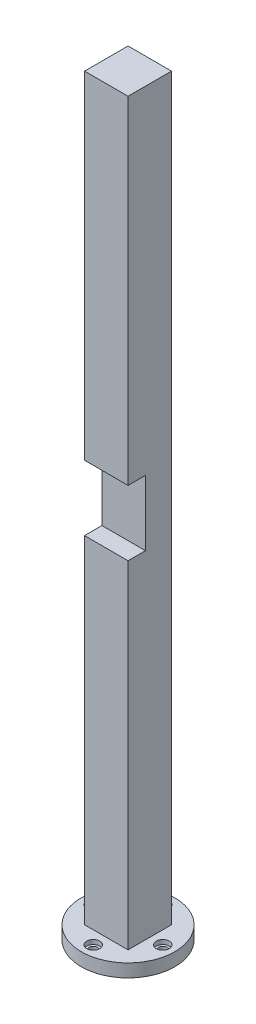
from build123d import *

# Parameters (mm, degrees)
SKETCH1_W           = 10
SKETCH1_H           = 10
BOSS_EXTRUDE1_DEPTH = 85
SKETCH2_W           = 10
SKETCH2_H           = 15
CUT_EXTRUDE1_DEPTH  = 4
SKETCH3_R           = 10.75
BOSS_EXTRUDE2_DEPTH = 3
SKETCH4_R           = 1
CUT_EXTRUDE2_DEPTH  = 3
SKETCH5_R           = 1.5
CUT_EXTRUDE3_DEPTH  = 1


with BuildPart() as part:
    # Sketch1 → Boss-Extrude1 (new body, symmetric)
    with BuildSketch(Plane(origin=(0, 0, 0), x_dir=(1, 0, 0), z_dir=(0, 1, 0))):
        Rectangle(SKETCH1_W, SKETCH1_H)
    extrude(amount=BOSS_EXTRUDE1_DEPTH, both=True)

    # Sketch2 → Cut-Extrude1 (cut)
    with BuildSketch(Plane.XY.offset(5)):
        Rectangle(SKETCH2_W, SKETCH2_H)
    extrude(amount=-CUT_EXTRUDE1_DEPTH, mode=Mode.SUBTRACT)

    # Sketch3 → Boss-Extrude2 (add)
    with BuildSketch(Plane.XZ.offset(85)):
        Circle(SKETCH3_R)
    extrude(amount=BOSS_EXTRUDE2_DEPTH)

    # Sketch4 → Cut-Extrude2 (cut)
    with BuildSketch(Plane(origin=(0, -85, 0), x_dir=(1, 0, 0), z_dir=(0, 1, 0))):
        with Locations((8, 0)):
            Circle(SKETCH4_R)
        with Locations((0, -8)):
            Circle(SKETCH4_R)
        with Locations((-8, 0)):
            Circle(SKETCH4_R)
        with Locations((0, 8)):
            Circle(SKETCH4_R)
    extrude(amount=-CUT_EXTRUDE2_DEPTH, mode=Mode.SUBTRACT)

    # Sketch5 → Cut-Extrude3 (cut)
    with BuildSketch(Plane(origin=(0, -85, 0), x_dir=(1, 0, 0), z_dir=(0, 1, 0))):
        with Locations((8, 0)):
            Circle(SKETCH5_R)
        with Locations((0, -8)):
            Circle(SKETCH5_R)
        with Locations((-8, 0)):
            Circle(SKETCH5_R)
        with Locations((0, 8)):
            Circle(SKETCH5_R)
    extrude(amount=-CUT_EXTRUDE3_DEPTH, mode=Mode.SUBTRACT)


solid = part.part
